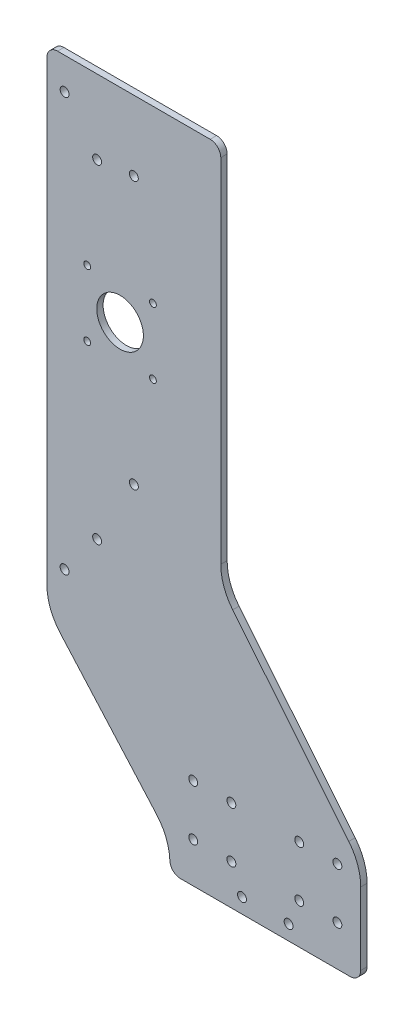
from build123d import *

# Parameters (mm, degrees)
SKETCH1_R           = 2.1
SKETCH1_R_2         = 11
SKETCH1_R_3         = 1.6
BOSS_EXTRUDE1_DEPTH = 1.5


with BuildPart() as part:
    # Sketch1 → Boss-Extrude1 (new body, symmetric)
    with BuildSketch(Plane.XY):
        with BuildLine():
            Line((107, -145), (107, -110.895624471))
            ThreePointArc((107, -110.895624471), (105.553363517, -102.514749396), (101.380874638, -95.103800692))
            Line((101.380874638, -95.103800692), (46.619125362, -27.896199308))
            ThreePointArc((46.619125362, -27.896199308), (42.446636483, -20.485250604), (41, -12.104375529))
            Line((41, -12.104375529), (41, 154))
            ThreePointArc((41, 154), (39.535533906, 157.535533906), (36, 159))
            Line((36, 159), (-36, 159))
            ThreePointArc((-36, 159), (-39.535533906, 157.535533906), (-41, 154))
            Line((-41, 154), (-41, -61.522167809))
            ThreePointArc((-41, -61.522167809), (-39.376465331, -70.384496434), (-34.716730508, -78.095761236))
            Line((-34.716730508, -78.095761236), (10.716730508, -129.404238764))
            ThreePointArc((10.716730508, -129.404238764), (15.198642313, -136.659946441), (16.980869565, -145))
            ThreePointArc((16.980869565, -145), (18.445335659, -148.535533906), (21.980869565, -150))
            Line((21.980869565, -150), (102, -150))
            ThreePointArc((102, -150), (105.535533906, -148.535533906), (107, -145))
        make_face()
        with Locations((96, -107)):
            Circle(SKETCH1_R, mode=Mode.SUBTRACT)
        with Locations((96, -131)):
            Circle(SKETCH1_R, mode=Mode.SUBTRACT)
        with Locations((78, -107)):
            Circle(SKETCH1_R, mode=Mode.SUBTRACT)
        with Locations((78, -131)):
            Circle(SKETCH1_R, mode=Mode.SUBTRACT)
        with Locations((46, -107)):
            Circle(SKETCH1_R, mode=Mode.SUBTRACT)
        with Locations((46, -131)):
            Circle(SKETCH1_R, mode=Mode.SUBTRACT)
        with Locations((28, -107)):
            Circle(SKETCH1_R, mode=Mode.SUBTRACT)
        with Locations((28, -131)):
            Circle(SKETCH1_R, mode=Mode.SUBTRACT)
        with Locations((51, -143)):
            Circle(SKETCH1_R, mode=Mode.SUBTRACT)
        with Locations((73, -143)):
            Circle(SKETCH1_R, mode=Mode.SUBTRACT)
        with Locations((0, 126)):
            Circle(SKETCH1_R, mode=Mode.SUBTRACT)
        Circle(SKETCH1_R, mode=Mode.SUBTRACT)
        with Locations((-32.666666667, 144)):
            Circle(SKETCH1_R, mode=Mode.SUBTRACT)
        with Locations((-17.333333333, 124)):
            Circle(SKETCH1_R, mode=Mode.SUBTRACT)
        with Locations((-17.333333333, -31)):
            Circle(SKETCH1_R, mode=Mode.SUBTRACT)
        with Locations((-32.666666667, -51)):
            Circle(SKETCH1_R, mode=Mode.SUBTRACT)
        with Locations((-6.5, 63)):
            Circle(SKETCH1_R_2, mode=Mode.SUBTRACT)
        with Locations((-22, 78.5)):
            Circle(SKETCH1_R_3, mode=Mode.SUBTRACT)
        with Locations((9, 78.5)):
            Circle(SKETCH1_R_3, mode=Mode.SUBTRACT)
        with Locations((-22, 47.5)):
            Circle(SKETCH1_R_3, mode=Mode.SUBTRACT)
        with Locations((9, 47.5)):
            Circle(SKETCH1_R_3, mode=Mode.SUBTRACT)
    extrude(amount=BOSS_EXTRUDE1_DEPTH, both=True)


solid = part.part
